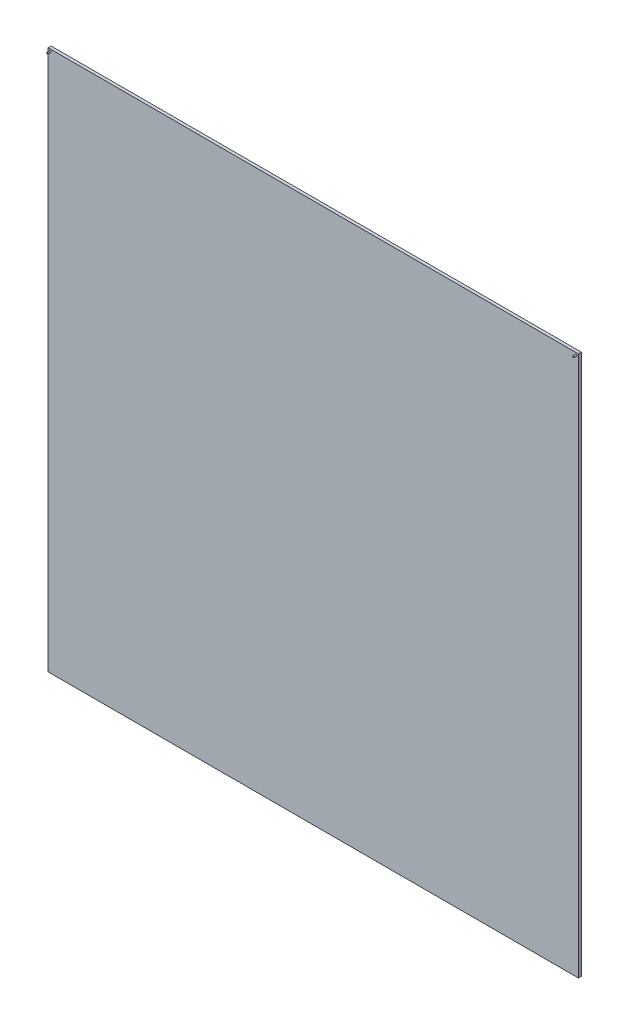
from build123d import *

# Parameters (mm, degrees)
SKETCH1_W           = 1797.766953
SKETCH1_H           = 1832.766953
BOSS_EXTRUDE1_DEPTH = 10
SKETCH2_R           = 2.5
BOSS_EXTRUDE2_DEPTH = 10


with BuildPart() as part:
    # Sketch1 → Boss-Extrude1 (new body)
    with BuildSketch(Plane.XY):
        with Locations((883.8834765, 866.3834765)):
            Rectangle(SKETCH1_W, SKETCH1_H)
    extrude(amount=BOSS_EXTRUDE1_DEPTH)

    # Sketch2 → Boss-Extrude2 (add)
    with BuildSketch(Plane.XY.offset(10)):
        with Locations((-7.5, 1775.266953)):
            Circle(SKETCH2_R)
        with Locations((1775.266953, 1775.266953)):
            Circle(SKETCH2_R)
    extrude(amount=BOSS_EXTRUDE2_DEPTH)


solid = part.part
